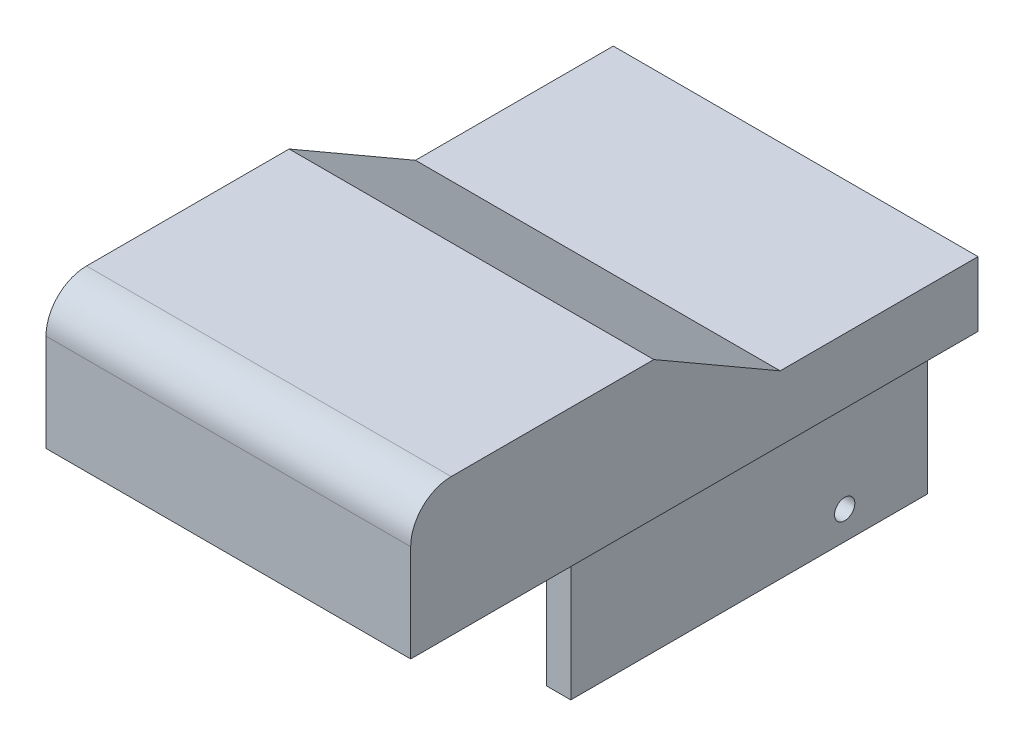
from build123d import *

# Parameters (mm, degrees)
BOSS_EXTRUDE1_DEPTH = 22.5
SKETCH2_W           = 3
SKETCH2_H           = 44
BOSS_EXTRUDE2_DEPTH = 20.5
SKETCH3_R           = 1.25
CUT_EXTRUDE1_DEPTH  = 39.75


with BuildPart() as part:
    # Sketch1 → Boss-Extrude1 (new body, symmetric)
    with BuildSketch(Plane(origin=(0, 0, 0), x_dir=(0, 0, -1), z_dir=(1, 0, 0))):
        with BuildLine():
            Line((5, 0), (30, 0))
            Line((30, 0), (45.588457268, -9))
            Line((45.588457268, -9), (70, -9))
            Line((70, -9), (70, -17))
            Line((70, -17), (63.318457268, -17))
            Line((63.318457268, -17), (0, -17))
            Line((0, -17), (0, -5))
            ThreePointArc((0, -5), (1.464466094, -1.464466094), (5, 0))
        make_face()
    extrude(amount=BOSS_EXTRUDE1_DEPTH, both=True)

    # Sketch2 → Boss-Extrude2 (add)
    with BuildSketch(Plane.XZ.offset(17)):
        with Locations((14.75, -48)):
            Rectangle(SKETCH2_W, SKETCH2_H)
        with Locations((-14.75, -48)):
            Rectangle(SKETCH2_W, SKETCH2_H)
    extrude(amount=BOSS_EXTRUDE2_DEPTH)

    # Sketch3 → Cut-Extrude1 (cut, through all)
    with BuildSketch(Plane.ZY.offset(16.25)):
        with Locations((-59.8, -34)):
            Circle(SKETCH3_R)
        with Locations((-39.5, -20.5)):
            Circle(SKETCH3_R)
    extrude(amount=-CUT_EXTRUDE1_DEPTH, mode=Mode.SUBTRACT)


solid = part.part
